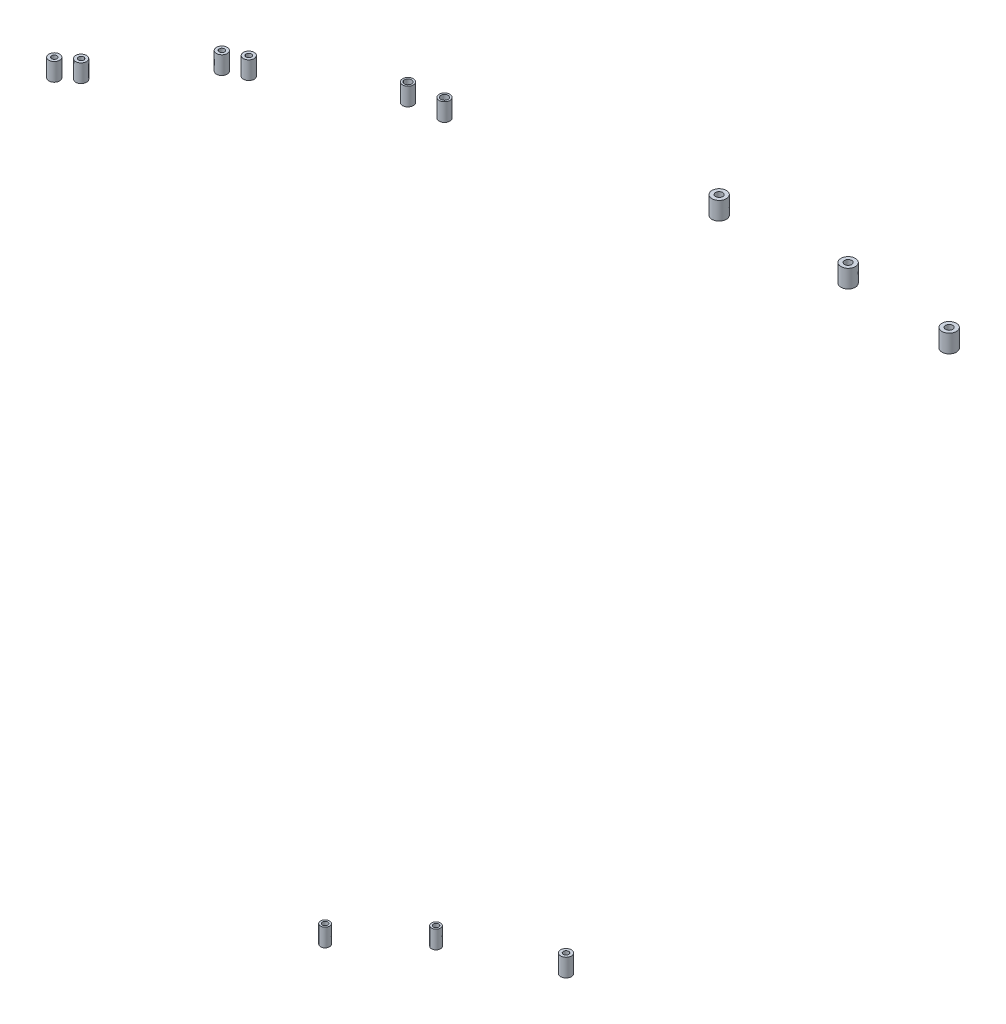
from build123d import *

# Parameters (mm, degrees)
SZKIC1_R                      = 3
SZKIC1_R_2                    = 1.5
DODANIE_WYCI_GNI_CIE1_DEPTH   = 10
DODANIE_WYCI_GNI_CIE1_2_DEPTH = 10
DODANIE_WYCI_GNI_CIE1_3_DEPTH = 10
DODANIE_WYCI_GNI_CIE1_4_DEPTH = 10
SZKIC1_R_3                    = 2
DODANIE_WYCI_GNI_CIE1_5_DEPTH = 10
DODANIE_WYCI_GNI_CIE1_6_DEPTH = 10
SZKIC1_R_4                    = 4
DODANIE_WYCI_GNI_CIE1_7_DEPTH = 10
DODANIE_WYCI_GNI_CIE1_8_DEPTH = 10
DODANIE_WYCI_GNI_CIE1_9_DEPTH = 10
SZKIC2_R                      = 2.5
SZKIC2_R_2                    = 1.5
DODANIE_WYCI_GNI_CIE2_DEPTH   = 10
DODANIE_WYCI_GNI_CIE2_2_DEPTH = 10
SZKIC2_R_3                    = 3
DODANIE_WYCI_GNI_CIE2_3_DEPTH = 10


with BuildPart() as part:
    # Szkic1 → Dodanie-wyciągnięcie1 (new body)
    with BuildSketch(Plane(origin=(0, 700, 0), x_dir=(1, 0, 0), z_dir=(0, 1, 0))):
        with Locations((-474.446759549, -382.68779999)):
            Circle(SZKIC1_R)
        with Locations((-474.446759549, -382.68779999)):
            Circle(SZKIC1_R_2, mode=Mode.SUBTRACT)
    extrude(amount=-DODANIE_WYCI_GNI_CIE1_DEPTH)


with BuildPart() as body_2:
    # Szkic1 → Dodanie-wyci_gni_cie1 2 (new body)
    with BuildSketch(Plane(origin=(0, 700, 0), x_dir=(1, 0, 0), z_dir=(0, 1, 0))):
        with Locations((-466.308050674, -375.85941501)):
            Circle(SZKIC1_R)
        with Locations((-466.308050674, -375.85941501)):
            Circle(SZKIC1_R_2, mode=Mode.SUBTRACT)
    extrude(amount=-DODANIE_WYCI_GNI_CIE1_2_DEPTH)


with BuildPart() as body_3:
    # Szkic1 → Dodanie-wyci_gni_cie1 3 (new body)
    with BuildSketch(Plane(origin=(0, 700, 0), x_dir=(1, 0, 0), z_dir=(0, 1, 0))):
        with Locations((-431.039698402, -332.774189517)):
            Circle(SZKIC1_R)
        with Locations((-431.039698402, -332.774189517)):
            Circle(SZKIC1_R_2, mode=Mode.SUBTRACT)
    extrude(amount=-DODANIE_WYCI_GNI_CIE1_3_DEPTH)


with BuildPart() as body_4:
    # Szkic1 → Dodanie-wyci_gni_cie1 4 (new body)
    with BuildSketch(Plane(origin=(0, 700, 0), x_dir=(1, 0, 0), z_dir=(0, 1, 0))):
        with Locations((-421.090050281, -327.725114352)):
            Circle(SZKIC1_R)
        with Locations((-421.090050281, -327.725114352)):
            Circle(SZKIC1_R_2, mode=Mode.SUBTRACT)
    extrude(amount=-DODANIE_WYCI_GNI_CIE1_4_DEPTH)


with BuildPart() as body_5:
    # Szkic1 → Dodanie-wyci_gni_cie1 5 (new body)
    with BuildSketch(Plane(origin=(0, 700, 0), x_dir=(1, 0, 0), z_dir=(0, 1, 0))):
        with Locations((-364.051137421, -296.101801859)):
            Circle(SZKIC1_R)
        with Locations((-364.051137421, -296.101801859)):
            Circle(SZKIC1_R_3, mode=Mode.SUBTRACT)
    extrude(amount=-DODANIE_WYCI_GNI_CIE1_5_DEPTH)


with BuildPart() as body_6:
    # Szkic1 → Dodanie-wyci_gni_cie1 6 (new body)
    with BuildSketch(Plane(origin=(0, 700, 0), x_dir=(1, 0, 0), z_dir=(0, 1, 0))):
        with Locations((-346.389872513, -293.396246383)):
            Circle(SZKIC1_R)
        with Locations((-346.389872513, -293.396246383)):
            Circle(SZKIC1_R_3, mode=Mode.SUBTRACT)
    extrude(amount=-DODANIE_WYCI_GNI_CIE1_6_DEPTH)


with BuildPart() as body_7:
    # Szkic1 → Dodanie-wyci_gni_cie1 7 (new body)
    with BuildSketch(Plane(origin=(0, 700, 0), x_dir=(1, 0, 0), z_dir=(0, 1, 0))):
        with Locations((-223.024834581, -263.802212936)):
            Circle(SZKIC1_R_4)
        with Locations((-223.024834581, -263.802212936)):
            Circle(SZKIC1_R_3, mode=Mode.SUBTRACT)
    extrude(amount=-DODANIE_WYCI_GNI_CIE1_7_DEPTH)


with BuildPart() as body_8:
    # Szkic1 → Dodanie-wyci_gni_cie1 8 (new body)
    with BuildSketch(Plane(origin=(0, 700, 0), x_dir=(1, 0, 0), z_dir=(0, 1, 0))):
        with Locations((-154.344703344, -260.643821632)):
            Circle(SZKIC1_R_4)
        with Locations((-154.344703344, -260.643821632)):
            Circle(SZKIC1_R_3, mode=Mode.SUBTRACT)
    extrude(amount=-DODANIE_WYCI_GNI_CIE1_8_DEPTH)


with BuildPart() as body_9:
    # Szkic1 → Dodanie-wyci_gni_cie1 9 (new body)
    with BuildSketch(Plane(origin=(0, 700, 0), x_dir=(1, 0, 0), z_dir=(0, 1, 0))):
        with Locations((-94.909521544, -263.802212936)):
            Circle(SZKIC1_R_4)
        with Locations((-94.909521544, -263.802212936)):
            Circle(SZKIC1_R_3, mode=Mode.SUBTRACT)
    extrude(amount=-DODANIE_WYCI_GNI_CIE1_9_DEPTH)


with BuildPart() as body_10:
    # Szkic2 → Dodanie-wyciągnięcie2 (new body)
    with BuildSketch(Plane(origin=(0, 310.2, 0), x_dir=(1, 0, 0), z_dir=(0, 1, 0))):
        with Locations((-370.956911026, -335.367132453)):
            Circle(SZKIC2_R)
        with Locations((-370.956911026, -335.367132453)):
            Circle(SZKIC2_R_2, mode=Mode.SUBTRACT)
    extrude(amount=-DODANIE_WYCI_GNI_CIE2_DEPTH)


with BuildPart() as body_11:
    # Szkic2 → Dodanie-wyci_gni_cie2 2 (new body)
    with BuildSketch(Plane(origin=(0, 310.2, 0), x_dir=(1, 0, 0), z_dir=(0, 1, 0))):
        with Locations((-339.082998521, -305.429754446)):
            Circle(SZKIC2_R)
        with Locations((-339.082998521, -305.429754446)):
            Circle(SZKIC2_R_2, mode=Mode.SUBTRACT)
    extrude(amount=-DODANIE_WYCI_GNI_CIE2_2_DEPTH)


with BuildPart() as body_12:
    # Szkic2 → Dodanie-wyci_gni_cie2 3 (new body)
    with BuildSketch(Plane(origin=(0, 310.2, 0), x_dir=(1, 0, 0), z_dir=(0, 1, 0))):
        with Locations((-289.68705591, -282.424125213)):
            Circle(SZKIC2_R_3)
        with Locations((-289.68705591, -282.424125213)):
            Circle(SZKIC2_R_2, mode=Mode.SUBTRACT)
    extrude(amount=-DODANIE_WYCI_GNI_CIE2_3_DEPTH)


solid = Compound([part.part, body_2.part, body_3.part, body_4.part, body_5.part, body_6.part, body_7.part, body_8.part, body_9.part, body_10.part, body_11.part, body_12.part])
